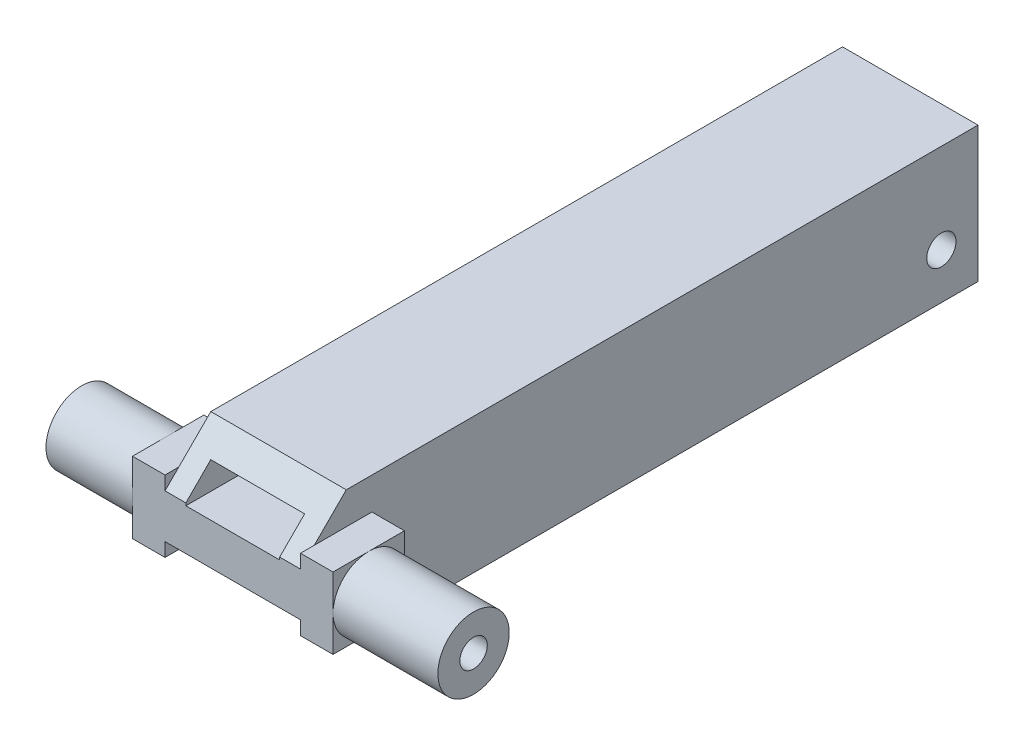
from build123d import *

# Parameters (mm, degrees)
SKETCH_1_W          = 74
SKETCH_1_H          = 14.8
EXTRUDE_1_DEPTH     = 14.8
SKETCH_2_W          = 10.25
SKETCH_2_H          = 10.25
CUT_EXTRUDE_1_DEPTH = 65
SKETCH_3_R          = 3.9
EXTRUDE_2_DEPTH     = 15
SKETCH_4_R          = 3.9
EXTRUDE_3_DEPTH     = 13
CHAMFER_1_SIZE      = 5
SKETCH_8_R          = 1.45
CUT_EXTRUDE_4_DEPTH = 43.8
SKETCH_9_W          = 7.8
SKETCH_9_H          = 7.8
SKETCH_9_R          = 1.5
EXTRUDE_4_DEPTH     = 3.55
SKETCH_10_W         = 7.8
SKETCH_10_H         = 7.8
EXTRUDE_5_DEPTH     = 3.55
SKETCH1_R           = 1.6
CUT_EXTRUDE1_DEPTH  = 30.8
SKETCH2_R           = 1.5
CUT_EXTRUDE2_DEPTH  = 43.8
SKETCH3_W           = 10.25
SKETCH3_H           = 3
CUT_EXTRUDE3_DEPTH  = 10


with BuildPart() as part:
    # Эскиз1 → Бобышка-Вытянуть1 (new body)
    with BuildSketch(Plane(origin=(0, 0, 0), x_dir=(0, 0, -1), z_dir=(1, 0, 0))):
        Rectangle(SKETCH_1_W, SKETCH_1_H)
    extrude(amount=EXTRUDE_1_DEPTH)

    # Эскиз2 → Вырез-Вытянуть1 (cut)
    with BuildSketch(Plane(origin=(0, 0, -37), x_dir=(-1, 0, 0), z_dir=(0, 0, -1))):
        with Locations((-7.4, 0)):
            Rectangle(SKETCH_2_W, SKETCH_2_H)
    extrude(amount=-CUT_EXTRUDE_1_DEPTH, mode=Mode.SUBTRACT)

    # Эскиз3 → Бобышка-Вытянуть2 (add)
    with BuildSketch(Plane(origin=(14.8, 0, 0), x_dir=(0, 0, -1), z_dir=(1, 0, 0))):
        with Locations((-33.1, 0)):
            Circle(SKETCH_3_R)
    extrude(amount=EXTRUDE_2_DEPTH)

    # Эскиз4 → Бобышка-Вытянуть3 (add)
    with BuildSketch(Plane.ZY):
        with Locations((33.1, 0)):
            Circle(SKETCH_4_R)
    extrude(amount=EXTRUDE_3_DEPTH)

    # Фаска1
    chamfer_1_edges = [part.edges().sort_by_distance(p)[0] for p in [
        (7.4, 7.4, 37),
        (7.4, -7.4, 37),
    ]]
    chamfer(chamfer_1_edges, length=CHAMFER_1_SIZE)

    # Эскиз8 → Вырез-Вытянуть4 (cut, through all)
    with BuildSketch(Plane(origin=(29.8, 0, 0), x_dir=(0, 0, -1), z_dir=(1, 0, 0))):
        with Locations((-33.1, 0)):
            Circle(SKETCH_8_R)
    extrude(amount=-CUT_EXTRUDE_4_DEPTH, mode=Mode.SUBTRACT)

    # Эскиз9 → Бобышка-Вытянуть4 (add)
    with BuildSketch(Plane.ZY):
        with Locations((33.1, 0)):
            Rectangle(SKETCH_9_W, SKETCH_9_H)
        with Locations((33.1, 0)):
            Circle(SKETCH_9_R, mode=Mode.SUBTRACT)
    extrude(amount=EXTRUDE_4_DEPTH)

    # Эскиз10 → Бобышка-Вытянуть5 (add)
    with BuildSketch(Plane(origin=(14.8, 0, 0), x_dir=(0, 0, -1), z_dir=(1, 0, 0))):
        with Locations((-33.1, 0)):
            Rectangle(SKETCH_10_W, SKETCH_10_H)
    extrude(amount=EXTRUDE_5_DEPTH)

    # Sketch1 → Cut-Extrude1 (cut, through all)
    with BuildSketch(Plane.ZY):
        with Locations((-33, -2.4)):
            Circle(SKETCH1_R)
    extrude(amount=-CUT_EXTRUDE1_DEPTH, mode=Mode.SUBTRACT)

    # Sketch2 → Cut-Extrude2 (cut, through all)
    with BuildSketch(Plane(origin=(29.8, 0, 0), x_dir=(0, 0, -1), z_dir=(1, 0, 0))):
        with Locations((-33.1, 0)):
            Circle(SKETCH2_R)
    extrude(amount=-CUT_EXTRUDE2_DEPTH, mode=Mode.SUBTRACT)

    # Sketch3 → Cut-Extrude3 (cut, through all)
    with BuildSketch(Plane(origin=(0, 0, 28), x_dir=(-1, 0, 0), z_dir=(0, 0, -1))):
        with Locations((-7.4, 3.625)):
            Rectangle(SKETCH3_W, SKETCH3_H)
    extrude(amount=-CUT_EXTRUDE3_DEPTH, mode=Mode.SUBTRACT)


solid = part.part
